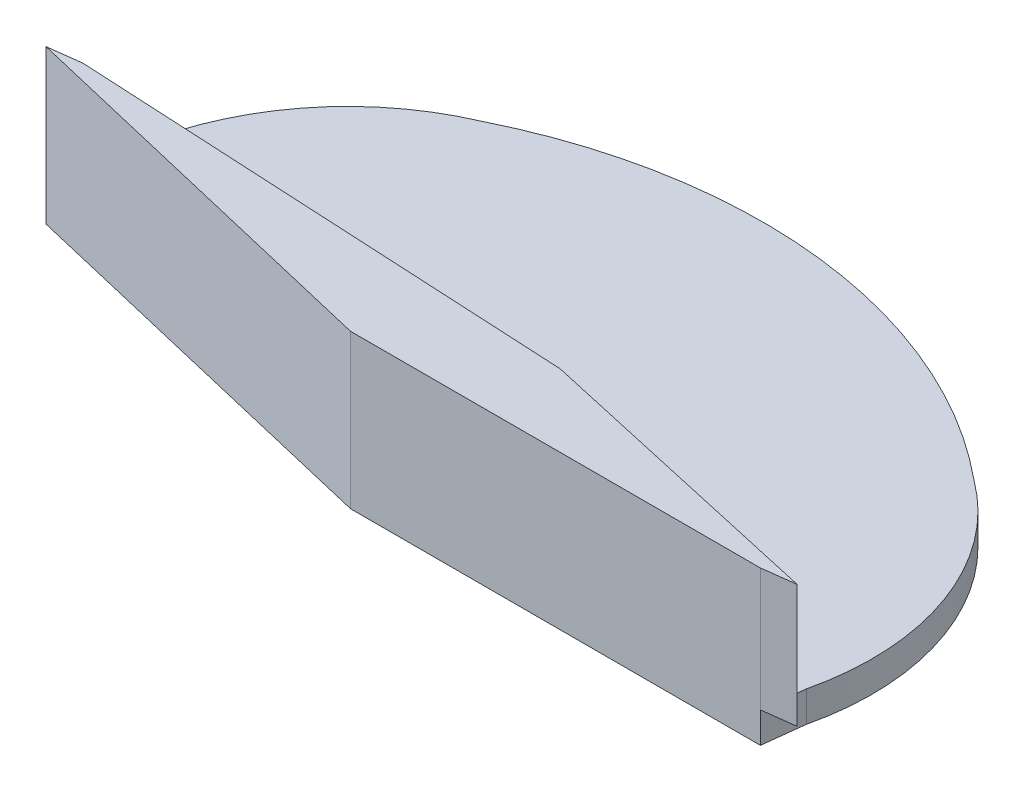
from build123d import *

# Parameters (mm, degrees)
SALIENTE_EXTRUIR2_DEPTH = 0.5
CORTAR_EXTRUIR1_DEPTH   = 0.5
CROQUIS10_R             = 1.5
SALIENTE_EXTRUIR5_DEPTH = 0.5
SALIENTE_EXTRUIR6_DEPTH = 6
SALIENTE_EXTRUIR8_DEPTH = 1


with BuildPart() as part:
    # Croquis2 → Saliente-Extruir2 (new body)
    with BuildSketch(Plane(origin=(0, 0, 0), x_dir=(1, 0, 0), z_dir=(0, 1, 0))):
        with BuildLine():
            Line((0, 0), (20, 0))
            Line((20, 0), (39.463577456, -4.600994744))
            ThreePointArc((39.463577456, -4.600994744), (39.040324802, 2.548287638), (34.753818463, 8.285642846))
            ThreePointArc((34.753818463, 8.285642846), (21.620038065, 13.895364206), (7.548005539, 11.457524625))
            ThreePointArc((7.548005539, 11.457524625), (2.056591074, 6.860161407), (0, 0))
        make_face()
    extrude(amount=SALIENTE_EXTRUIR2_DEPTH)

    # Croquis3 → Cortar-Extruir1 (cut)
    with BuildSketch(Plane(origin=(0, 0.5, 0), x_dir=(1, 0, 0), z_dir=(0, 1, 0))):
        with BuildLine():
            Line((20, 0), (16.5, 0))
            ThreePointArc((16.5, 0), (20.143291885, 1.229040833), (23.406126055, -0.80517408))
            Line((23.406126055, -0.80517408), (20, 0))
        make_face()
    extrude(amount=-CORTAR_EXTRUIR1_DEPTH, mode=Mode.SUBTRACT)

    # Croquis10 → Saliente-Extruir5 (add)
    with BuildSketch(Plane.XZ):
        Polygon((19.228440578, 6.617808668), (-0.235136993, 2.016814414), (0, 0), (19.62217394, -4.124844283), (39.463577456, 4.600994744), (39.228440578, 6.617808164), align=None)
        with Locations((19.622174052, 3.240683566)):
            Circle(CROQUIS10_R, mode=Mode.SUBTRACT)
    extrude(amount=-SALIENTE_EXTRUIR5_DEPTH)

    # Croquis11 → Saliente-Extruir6 (add)
    with BuildSketch(Plane(origin=(0, 0.5, 0), x_dir=(1, 0, 0), z_dir=(0, 1, 0))):
        Polygon((25.926575996, -3.088366571), (1.36009864, -1.814608984), (-0.235136987, -2.016814452), (19.228440593, -6.617808669), (39.228440593, -6.617808128), (40.823677784, -6.415602462), align=None)
    extrude(amount=SALIENTE_EXTRUIR6_DEPTH)

    # Croquis14 → Saliente-Extruir8 (add)
    with BuildSketch(Plane.XZ):
        with BuildLine():
            Line((39.463577456, 4.600994744), (39.228440578, 6.617808164))
            Line((39.228440578, 6.617808164), (19.228440578, 6.617808668))
            Line((19.228440578, 6.617808668), (-0.235136993, 2.016814414))
            Line((-0.235136993, 2.016814414), (0, 0))
            ThreePointArc((0, 0), (2.056591074, -6.860161407), (7.548005539, -11.457524625))
            ThreePointArc((7.548005539, -11.457524625), (21.620038065, -13.895364206), (34.753818463, -8.285642846))
            ThreePointArc((34.753818463, -8.285642846), (39.040324802, -2.548287638), (39.463577456, 4.600994744))
        make_face()
    extrude(amount=SALIENTE_EXTRUIR8_DEPTH)


solid = part.part
